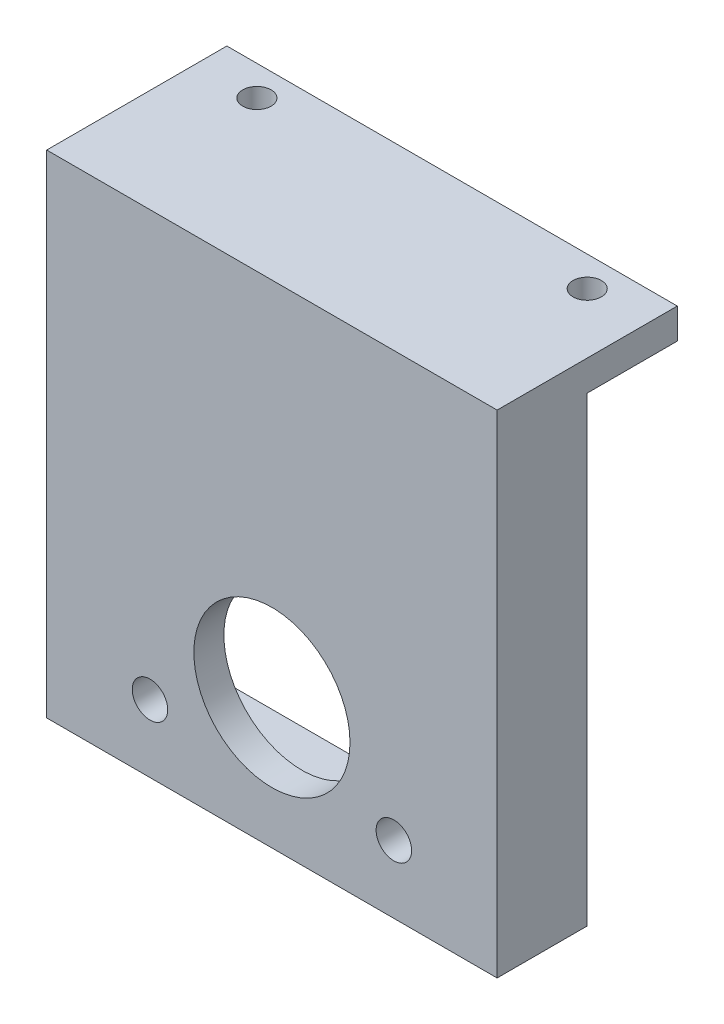
from build123d import *

# Parameters (mm, degrees)
SKETCH2_W               = 38.1
SKETCH2_H               = 41.6052
SKETCH2_W_2             = 33.02
SKETCH2_H_2             = 33.9852
BOSS_EXTRUDE1_DEPTH     = 5.08
BOSS_EXTRUDE2_DEPTH     = 7.62
M2_CLEARANCE_HOLE1_D    = 2.4
SKETCH8_W               = 38.1
SKETCH8_H               = 41.6052
SKETCH8_R               = 6.604
BOSS_EXTRUDE3_DEPTH     = 2.54
SKETCH7_R               = 1.50114
CUT_EXTRUDE1_DEPTH      = 3.54
CUT_EXTRUDE1_DEPTH_BACK = 13.7


with BuildPart() as part:
    # Sketch2 → Boss-Extrude1 (new body)
    with BuildSketch(Plane.XY):
        with Locations((0, 20.8026)):
            Rectangle(SKETCH2_W, SKETCH2_H)
        with Locations((0, 19.5326)):
            Rectangle(SKETCH2_W_2, SKETCH2_H_2, mode=Mode.SUBTRACT)
    extrude(amount=BOSS_EXTRUDE1_DEPTH)

    # Sketch4 → Boss-Extrude2 (add)
    with BuildSketch(Plane(origin=(0, 0, 0), x_dir=(-1, 0, 0), z_dir=(0, 0, -1))):
        Polygon((-19.05, 41.6052), (19.05, 41.6052), (19.05, 39.0652), (-19.05, 39.036199263), align=None)
    extrude(amount=BOSS_EXTRUDE2_DEPTH)

    # M2 Clearance Hole1 (through all)
    with Locations(Plane(origin=(0, 41.6052, 0), x_dir=(1, 0, 0), z_dir=(0, 1, 0))):
        with Locations((-13.97, 5.08), (13.97, 5.08)):
            Hole(M2_CLEARANCE_HOLE1_D / 2)

    # Sketch8 → Boss-Extrude3 (add)
    with BuildSketch(Plane.XY.offset(5.08)):
        with Locations((0, 20.8026)):
            Rectangle(SKETCH8_W, SKETCH8_H)
        with Locations((0, 11.02614)):
            Circle(SKETCH8_R, mode=Mode.SUBTRACT)
    extrude(amount=BOSS_EXTRUDE3_DEPTH)

    # Sketch7 → Cut-Extrude1 (cut, two sides)
    with BuildSketch(Plane.XY.offset(5.08)) as cut_extrude1_sk:
        with Locations((-10.31494, 5.715)):
            Circle(SKETCH7_R)
        with Locations((10.31494, 5.715)):
            Circle(SKETCH7_R)
    extrude(amount=CUT_EXTRUDE1_DEPTH, mode=Mode.SUBTRACT)
    extrude(cut_extrude1_sk.sketch, amount=-CUT_EXTRUDE1_DEPTH_BACK, mode=Mode.SUBTRACT)


solid = part.part
